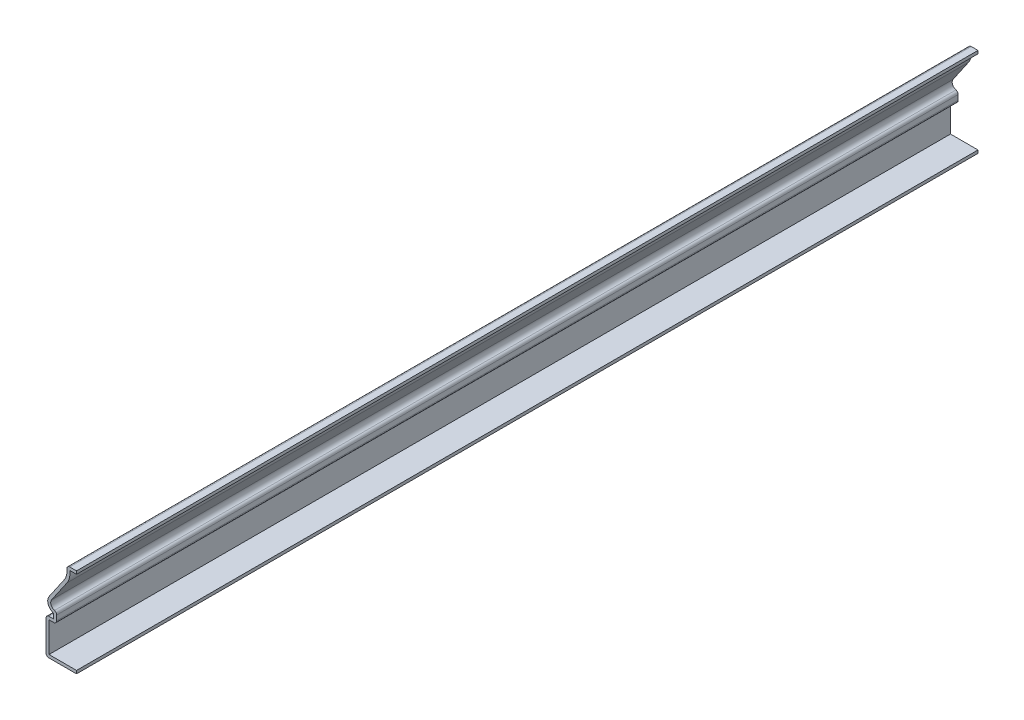
from build123d import *

# Parameters (mm, degrees)
EXTRUDE_THIN1_DEPTH = 304.8
FILLET1_R           = 1.016


with BuildPart() as part:
    # Sketch1 → Extrude-Thin1 (new body)
    with BuildSketch(Plane.XY):
        with BuildLine():
            Line((0, 0), (-10.31875, 0))
            Line((-10.31875, 0), (-10.31875, 12.199518022))
            Line((-10.31875, 12.199518022), (-7.726000141, 12.199518022))
            Line((-7.726000141, 12.199518022), (-7.726000141, 13.878836266))
            ThreePointArc((-7.726000141, 13.878836266), (-9.572182479, 15.568472968), (-9.26085893, 18.051684409))
            Line((-9.26085893, 18.051684409), (-4.088758773, 25.580941853))
            ThreePointArc((-4.088758773, 25.580941853), (-3.258106429, 27.807165094), (-3.571875, 30.1625))
            Line((-3.571875, 30.1625), (0, 30.1625))
            Line((0, 30.1625), (0, 29.1465))
            Line((0, 29.1465), (-2.264128397, 29.1465))
            ThreePointArc((-2.264128397, 29.1465), (-2.372545269, 26.984258971), (-3.251310814, 25.005670685))
            Line((-3.251310814, 25.005670685), (-8.423410971, 17.476413241))
            ThreePointArc((-8.423410971, 17.476413241), (-8.449647278, 15.58096036), (-6.710000141, 14.827927951))
            Line((-6.710000141, 14.827927951), (-6.710000141, 11.183518022))
            Line((-6.710000141, 11.183518022), (-9.30275, 11.183518022))
            Line((-9.30275, 11.183518022), (-9.30275, 1.016))
            Line((-9.30275, 1.016), (0, 1.016))
            Line((0, 1.016), (0, 0))
        make_face()
    extrude(amount=-EXTRUDE_THIN1_DEPTH)

    # Fillet1
    fillet1_edges = [part.edges().sort_by_distance(p)[0] for p in [
        (-10.31875, 0, -152.4),
        (-10.31875, 12.199518022, -152.4),
        (-3.571875, 30.1625, -152.4),
        (-6.710000141, 14.827927951, -152.4),
        (-6.710000141, 11.183518022, -152.4),
    ]]
    fillet(fillet1_edges, radius=FILLET1_R)


solid = part.part
